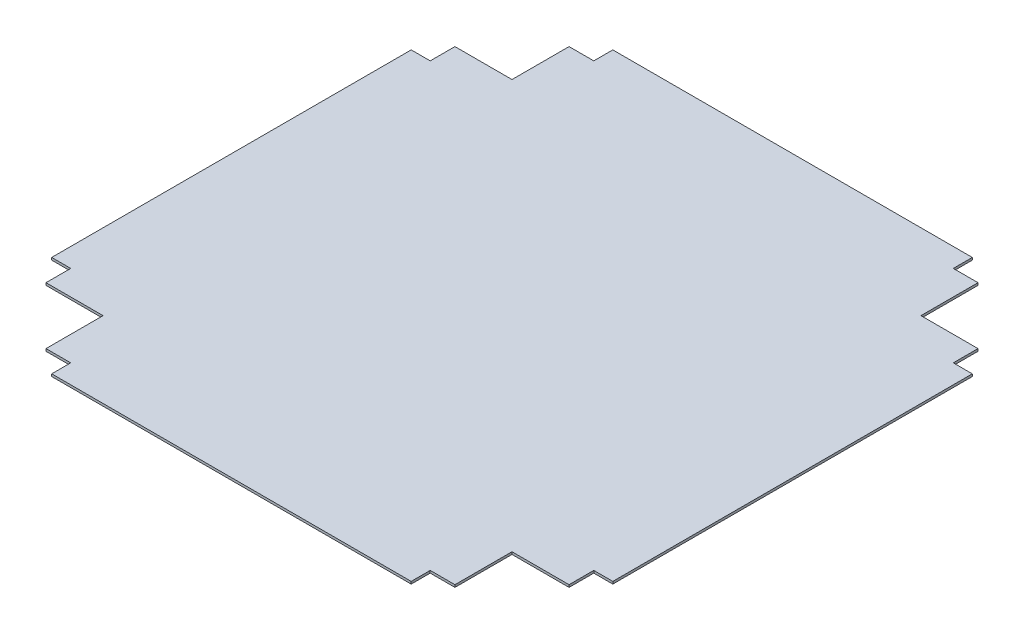
from build123d import *

# Parameters (mm, degrees)
BOSS_EXTRUDE1_DEPTH = 3.175


with BuildPart() as part:
    # Sketch1 → Boss-Extrude1 (new body)
    with BuildSketch(Plane(origin=(0, 0, 0), x_dir=(1, 0, 0), z_dir=(0, 1, 0))):
        Polygon((240.03, 374.65), (-240.03, 374.65), (-240.03, 349.25), (-273.05, 349.25), (-273.05, 273.05), (-349.25, 273.05), (-349.25, 240.03), (-374.65, 240.03), (-374.65, -240.03), (-349.25, -240.03), (-349.25, -273.05), (-273.05, -273.05), (-273.05, -349.25), (-240.03, -349.25), (-240.03, -374.65), (240.03, -374.65), (240.03, -349.25), (273.05, -349.25), (273.05, -273.05), (349.25, -273.05), (349.25, -240.03), (374.65, -240.03), (374.65, 240.03), (349.25, 240.03), (349.25, 273.05), (273.05, 273.05), (273.05, 349.25), (240.03, 349.25), align=None)
    extrude(amount=BOSS_EXTRUDE1_DEPTH)


solid = part.part
